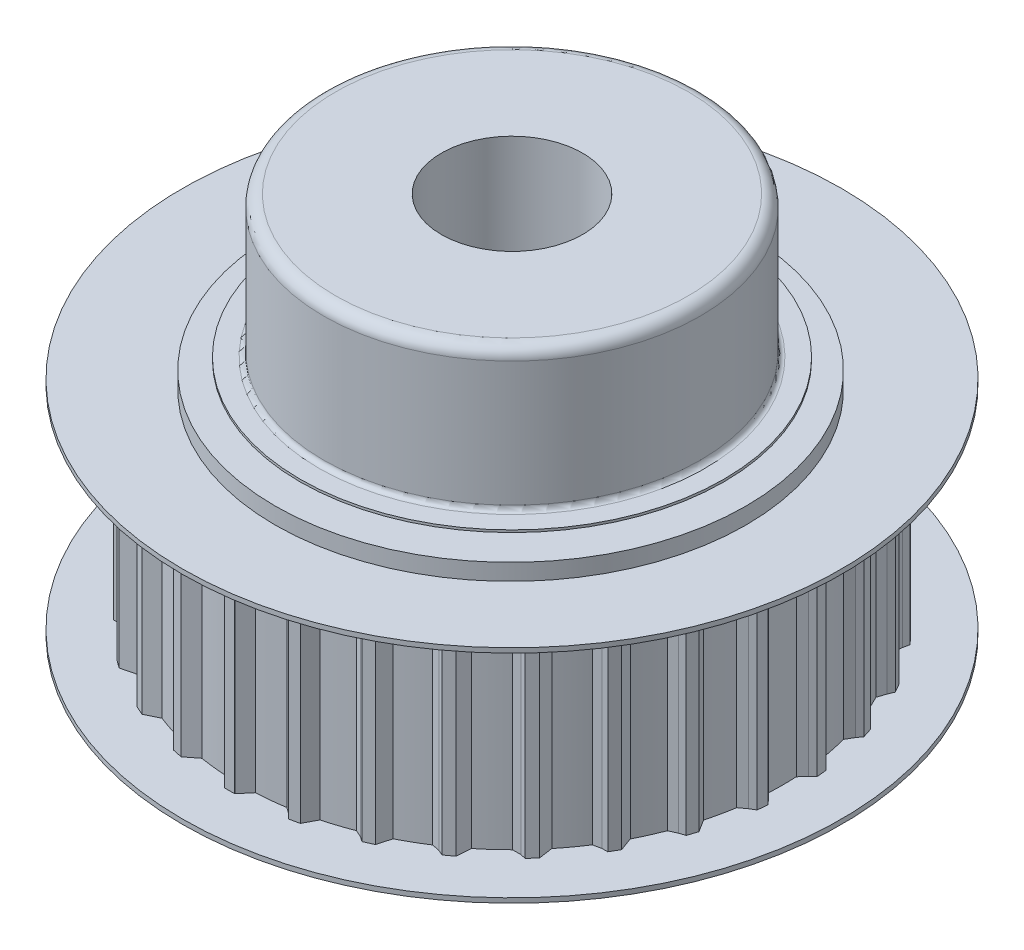
from build123d import *

# Parameters (mm, degrees)
ESQUISSE1_R             = 11.5
BOSS_EXTRU_1_DEPTH      = 9
BOSS_EXTRU_3_DEPTH      = 9
ESQUISSE3_R             = 14
BOSS_EXTRU_4_DEPTH      = 0.2
ESQUISSE4_R             = 10
BOSS_EXTRU_5_DEPTH      = 0.7
ESQUISSE5_R             = 9
BOSS_EXTRU_6_DEPTH      = 0.1
ESQUISSE6_R             = 14
BOSS_EXTRU_7_DEPTH      = 0.2
ESQUISSE7_R             = 10
BOSS_EXTRU_8_DEPTH      = 0.7
ESQUISSE8_R             = 9
BOSS_EXTRU_9_DEPTH      = 0.1
ESQUISSE9_R             = 8
BOSS_EXTRU_10_DEPTH     = 6
CONG_1_R                = 0.5
CONG_2_R                = 0.2
ESQUISSE10_R            = 3
ENL_V_MAT_EXTRU_1_DEPTH = 18


with BuildPart() as part:
    # Esquisse1 → Boss.-Extru.1 (new body)
    with BuildSketch(Plane(origin=(0, 0, 0), x_dir=(1, 0, 0), z_dir=(0, 1, 0))):
        Circle(ESQUISSE1_R)
    extrude(amount=BOSS_EXTRU_1_DEPTH)

    # Esquisse2 → Boss.-Extru.3 (add)
    with BuildSketch(Plane(origin=(0, 9, 0), x_dir=(1, 0, 0), z_dir=(0, 1, 0))):
        Polygon((-0.216665367, 12), (0.215023959, 12), (0.65, 11.48161574), (-0.65, 11.48161574), (-0.216665367, 11.998043846), align=None)
        Polygon((2.278589279, 11.779606934), (2.700845157, 11.689853676), (2.775539392, 11.459968458), (3.01853778, 11.092360752), (1.746945899, 11.36264595), (2.278182571, 11.777693526), align=None)
        Polygon((4.673494328, 11.045237373), (5.067862151, 10.869653506), (5.093128314, 10.629262027), (5.254386664, 10.219165225), (4.066777569, 10.747922861), (4.672698689, 11.043450337), align=None)
        Polygon((6.86338094, 9.82898679), (7.212624941, 9.575246171), (7.21565499, 9.314296291), (7.259829327, 8.900191993), (6.208107234, 9.664312821), (6.862231141, 9.827404228), align=None)
        Polygon((8.75254056, 8.184011173), (9.0413971, 7.863203485), (8.990106404, 7.607326002), (8.947218302, 7.193086516), (8.077348513, 8.159174789), (8.751086853, 8.18270225), align=None)
        Polygon((10.258407847, 6.182203849), (10.47425251, 5.808349927), (10.370882719, 5.568727916), (10.242806592, 5.172457495), (9.592806592, 6.29829052), (10.256713768, 6.181225772), align=None)
        Polygon((11.315169176, 3.911053404), (11.448568514, 3.500492458), (11.297637384, 3.287598552), (11.089970774, 2.926616113), (10.688248682, 4.162989585), (11.313308762, 3.910448919), align=None)
        Polygon((11.876639005, 1.469820011), (11.921762827, 1.040495524), (11.729866772, 0.863634207), (11.451685707, 0.553716417), (11.315798705, 1.846594881), (11.874693567, 1.469615537), align=None)
        Polygon((11.918278409, -1.034802717), (11.873154587, -1.464127204), (11.648680386, -1.597226244), (11.312142713, -1.842534491), (11.448029715, -0.549656027), (11.916332971, -1.034598244), align=None)
        Polygon((11.438267546, -3.493350748), (11.304868208, -3.903911695), (11.05762646, -3.987431391), (10.67744049, -4.157408947), (11.079162583, -2.921035476), (11.436407132, -3.492746263), align=None)
        Polygon((10.457585193, -5.798373736), (10.241740531, -6.172227659), (10.000024908, -6.172227659), (9.592806592, -6.25944569), (10.225318572, -5.163902806), (10.455891114, -5.797395659), align=None)
        Polygon((9.019091877, -7.849131115), (8.730235336, -8.169938804), (8.49380178, -8.1196833), (8.077348513, -8.12032996), (8.923814762, -7.180233951), (9.017638171, -7.847822192), align=None)
        Polygon((7.185656656, -9.555994948), (6.836412655, -9.809735567), (6.615594446, -9.711420966), (6.208107234, -9.625467992), (7.231533115, -8.881905565), (7.184506857, -9.554412385), align=None)
        Polygon((5.037409449, -10.844367093), (4.643041626, -11.01995096), (4.447489579, -10.877874082), (4.066777569, -10.709078031), (5.22243446, -10.194546433), (5.036613809, -10.842580057), align=None)
        Polygon((2.668238966, -11.657939507), (2.245983087, -11.747692765), (2.084243766, -11.56806305), (1.746945899, -11.323801121), (2.984326049, -11.060787851), (2.667832258, -11.656026099), align=None)
        Polygon((0.181689326, -11.961155171), (-0.25, -11.961155171), (-0.370857811, -11.751823301), (-0.65, -11.442770911), (0.615023959, -11.442770911), (0.181689326, -11.959199016), align=None)
        Polygon((-2.31356532, -11.740762105), (-2.735821198, -11.651008847), (-2.810515433, -11.421123629), (-3.01930209, -11.060787851), (-1.78192194, -11.323801121), (-2.313158613, -11.738848697), align=None)
        Polygon((-4.70847037, -11.006392544), (-5.102838192, -10.830808676), (-5.128104355, -10.590417197), (-5.257410502, -10.194546433), (-4.101753611, -10.709078031), (-4.70767473, -11.004605508), align=None)
        Polygon((-6.898356981, -9.790141961), (-7.247600982, -9.536401342), (-7.222334819, -9.296009863), (-7.266509157, -8.881905565), (-6.243083276, -9.625467992), (-6.897207182, -9.788559399), align=None)
        Polygon((-8.787516601, -8.145166344), (-9.076373141, -7.824358655), (-9.001678906, -7.594473437), (-8.958790803, -7.180233951), (-8.112324555, -8.12032996), (-8.786062895, -8.143857421), align=None)
        Polygon((-10.293383888, -6.14335902), (-10.509228551, -5.769505097), (-10.38837074, -5.560173228), (-10.260294613, -5.163902806), (-9.627782634, -6.25944569), (-10.291689809, -6.142380943), align=None)
        Polygon((-11.350145217, -3.872208575), (-11.483544555, -3.461647629), (-11.321805234, -3.282017914), (-11.114138625, -2.921035476), (-10.723224723, -4.124144755), (-11.348284804, -3.87160409), align=None)
        Polygon((-11.911615047, -1.430975181), (-11.956738868, -1.001650695), (-11.761186822, -0.859573817), (-11.483005757, -0.549656027), (-11.350774746, -1.807750052), (-11.909669608, -1.430770708), align=None)
        Polygon((-11.95325445, 1.073647547), (-11.908130629, 1.502972033), (-11.68731242, 1.601286634), (-11.350774746, 1.846594881), (-11.483005757, 0.588500856), (-11.951309012, 1.073443073), align=None)
        Polygon((-11.473243587, 3.532195578), (-11.339844249, 3.942756524), (-11.103410693, 3.993012028), (-10.712416532, 4.196253777), (-11.114138625, 2.959880305), (-11.471383174, 3.531591093), align=None)
        Polygon((-10.492561235, 5.837218565), (-10.276716572, 6.211072488), (-10.035000949, 6.211072488), (-9.610294613, 6.32858066), (-10.260294613, 5.202747635), (-10.490867155, 5.836240488), align=None)
        Polygon((-9.054067918, 7.887975945), (-8.765211378, 8.208783633), (-8.528777821, 8.158528129), (-8.088921015, 8.185167053), (-8.958790803, 7.21907878), (-9.052614212, 7.886667022), align=None)
        Polygon((-7.220632697, 9.594839777), (-6.871388697, 9.848580396), (-6.650570488, 9.750265795), (-6.214787064, 9.684871222), (-7.266509157, 8.920750394), (-7.219482899, 9.593257215), align=None)
        Polygon((-5.07238549, 10.883211922), (-4.678017667, 11.05879579), (-4.482465621, 10.916718911), (-4.069801407, 10.762148898), (-5.257410502, 10.233391262), (-5.07158985, 10.881424886), align=None)
        Polygon((-2.703215007, 11.696784336), (-2.280959129, 11.786537594), (-2.119219808, 11.60690788), (-1.747710209, 11.369917878), (-3.01930209, 11.09963268), (-2.7028083, 11.694870928), align=None)
    extrude(amount=-BOSS_EXTRU_3_DEPTH)

    # Esquisse3 → Boss.-Extru.4 (add)
    with BuildSketch(Plane(origin=(0, 9, 0), x_dir=(1, 0, 0), z_dir=(0, 1, 0))):
        Circle(ESQUISSE3_R)
    extrude(amount=BOSS_EXTRU_4_DEPTH)

    # Esquisse4 → Boss.-Extru.5 (add)
    with BuildSketch(Plane(origin=(0, 9.2, 0), x_dir=(1, 0, 0), z_dir=(0, 1, 0))):
        with Locations((0.35767124, -0.41735064)):
            Circle(ESQUISSE4_R)
    extrude(amount=BOSS_EXTRU_5_DEPTH)

    # Esquisse5 → Boss.-Extru.6 (add)
    with BuildSketch(Plane(origin=(0, 9.9, 0), x_dir=(1, 0, 0), z_dir=(0, 1, 0))):
        Circle(ESQUISSE5_R)
    extrude(amount=BOSS_EXTRU_6_DEPTH)

    # Esquisse6 → Boss.-Extru.7 (add)
    with BuildSketch(Plane.XZ):
        Circle(ESQUISSE6_R)
    extrude(amount=BOSS_EXTRU_7_DEPTH)

    # Esquisse7 → Boss.-Extru.8 (add)
    with BuildSketch(Plane(origin=(0, -0.2, 0), x_dir=(-1, 0, 0), z_dir=(0, -1, 0))):
        Circle(ESQUISSE7_R)
    extrude(amount=BOSS_EXTRU_8_DEPTH)

    # Esquisse8 → Boss.-Extru.9 (add)
    with BuildSketch(Plane(origin=(0, -0.9, 0), x_dir=(-1, 0, 0), z_dir=(0, -1, 0))):
        Circle(ESQUISSE8_R)
    extrude(amount=BOSS_EXTRU_9_DEPTH)

    # Esquisse9 → Boss.-Extru.10 (add)
    with BuildSketch(Plane(origin=(0, 10, 0), x_dir=(1, 0, 0), z_dir=(0, 1, 0))):
        Circle(ESQUISSE9_R)
    extrude(amount=BOSS_EXTRU_10_DEPTH)

    # Congé1
    cong_1_edges = [part.edges().sort_by_distance(p)[0] for p in [
        (-8, 16, 0),
    ]]
    fillet(cong_1_edges, radius=CONG_1_R)

    # Congé2
    cong_2_edges = [part.edges().sort_by_distance(p)[0] for p in [
        (-8, 10, 0),
    ]]
    fillet(cong_2_edges, radius=CONG_2_R)

    # Esquisse10 → Enlèv. mat.-Extru.1 (cut, through all)
    with BuildSketch(Plane(origin=(0, 16, 0), x_dir=(1, 0, 0), z_dir=(0, 1, 0))):
        Circle(ESQUISSE10_R)
    extrude(amount=-ENL_V_MAT_EXTRU_1_DEPTH, mode=Mode.SUBTRACT)


solid = part.part
